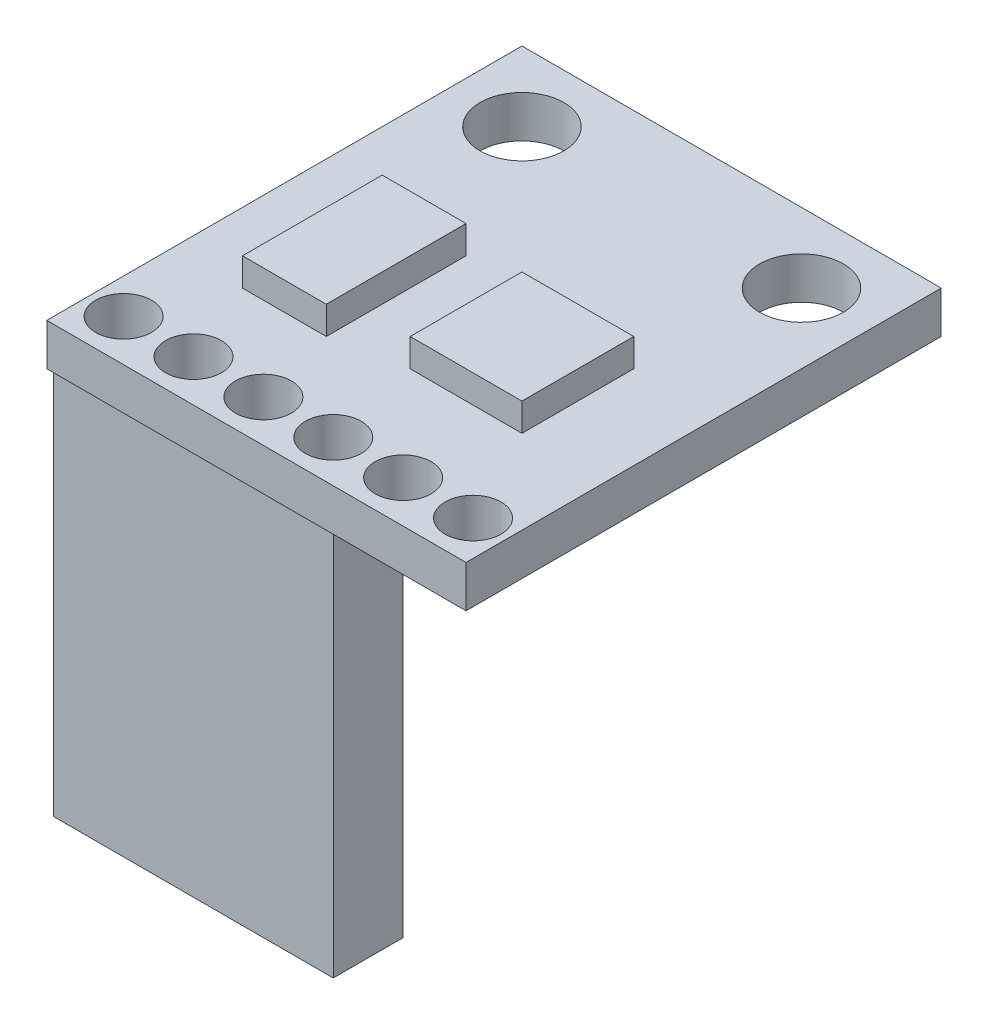
from build123d import *

# Parameters (mm, degrees)
ESQUISSE1_W        = 15
ESQUISSE1_H        = 17
ESQUISSE1_R        = 1.5
ESQUISSE1_R_2      = 1
BOSS_EXTRU_1_DEPTH = 1.5
ESQUISSE2_W        = 3
ESQUISSE2_H        = 5
ESQUISSE2_W_2      = 4
ESQUISSE2_H_2      = 4
BOSS_EXTRU_2_DEPTH = 1
ESQUISSE3_W        = 10
ESQUISSE3_H        = 2.5
BOSS_EXTRU_3_DEPTH = 14


with BuildPart() as part:
    # Esquisse1 → Boss.-Extru.1 (new body)
    with BuildSketch(Plane(origin=(0, 0, 0), x_dir=(1, 0, 0), z_dir=(0, 1, 0))):
        Rectangle(ESQUISSE1_W, ESQUISSE1_H)
        with Locations((-5, 6)):
            Circle(ESQUISSE1_R, mode=Mode.SUBTRACT)
        with Locations((5, 6)):
            Circle(ESQUISSE1_R, mode=Mode.SUBTRACT)
        with Locations((-6.25, -7)):
            Circle(ESQUISSE1_R_2, mode=Mode.SUBTRACT)
        with Locations((-3.75, -7)):
            Circle(ESQUISSE1_R_2, mode=Mode.SUBTRACT)
        with Locations((-1.25, -7)):
            Circle(ESQUISSE1_R_2, mode=Mode.SUBTRACT)
        with Locations((1.25, -7)):
            Circle(ESQUISSE1_R_2, mode=Mode.SUBTRACT)
        with Locations((3.75, -7)):
            Circle(ESQUISSE1_R_2, mode=Mode.SUBTRACT)
        with Locations((6.25, -7)):
            Circle(ESQUISSE1_R_2, mode=Mode.SUBTRACT)
    extrude(amount=BOSS_EXTRU_1_DEPTH)

    # Esquisse2 → Boss.-Extru.2 (add)
    with BuildSketch(Plane(origin=(0, 1.5, 0), x_dir=(1, 0, 0), z_dir=(0, 1, 0))):
        with Locations((-3.5, -1.5)):
            Rectangle(ESQUISSE2_W, ESQUISSE2_H)
        with Locations((2.5, -1.5)):
            Rectangle(ESQUISSE2_W_2, ESQUISSE2_H_2)
    extrude(amount=BOSS_EXTRU_2_DEPTH)

    # Esquisse3 → Boss.-Extru.3 (add)
    with BuildSketch(Plane.XZ):
        with Locations((-2.5, 7)):
            Rectangle(ESQUISSE3_W, ESQUISSE3_H)
    extrude(amount=BOSS_EXTRU_3_DEPTH)


solid = part.part
